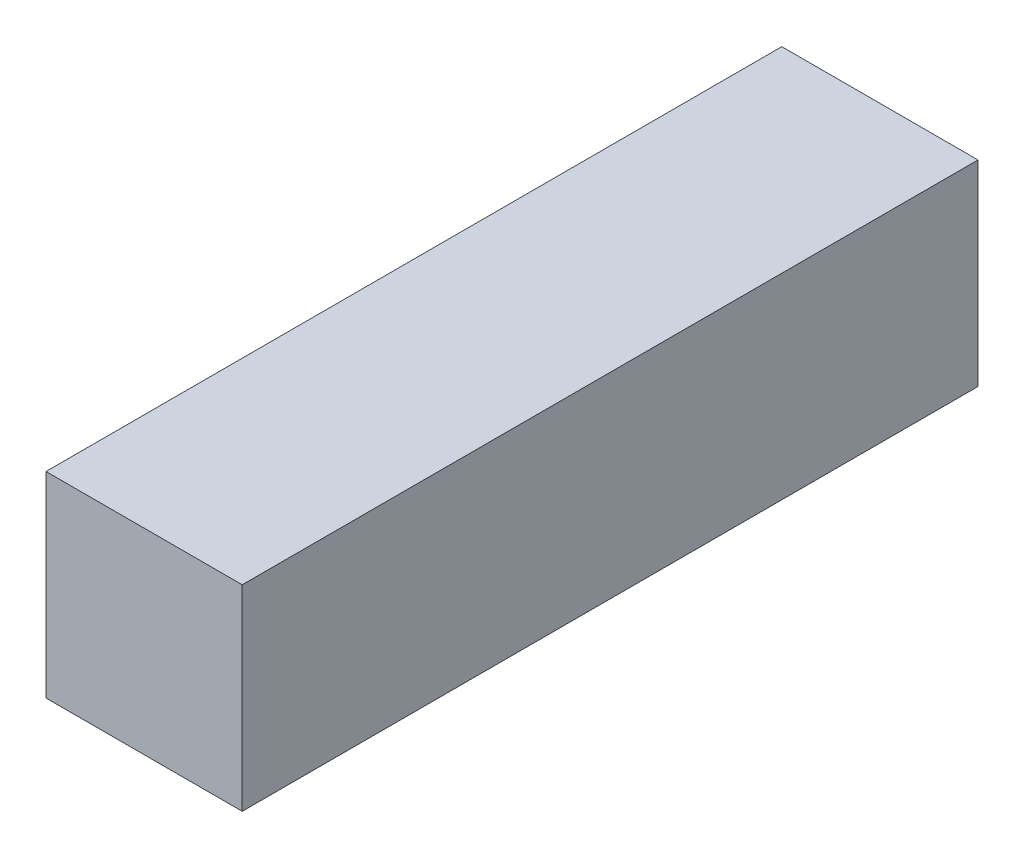
from build123d import *

# Parameters (mm, degrees)
SKETCH7_W           = 20.32
SKETCH7_H           = 20.32
BOSS_EXTRUDE3_DEPTH = 38.1


with BuildPart() as part:
    # Sketch7 → Boss-Extrude3 (new body, symmetric)
    with BuildSketch(Plane.XY):
        Rectangle(SKETCH7_W, SKETCH7_H)
    extrude(amount=BOSS_EXTRUDE3_DEPTH, both=True)


solid = part.part
